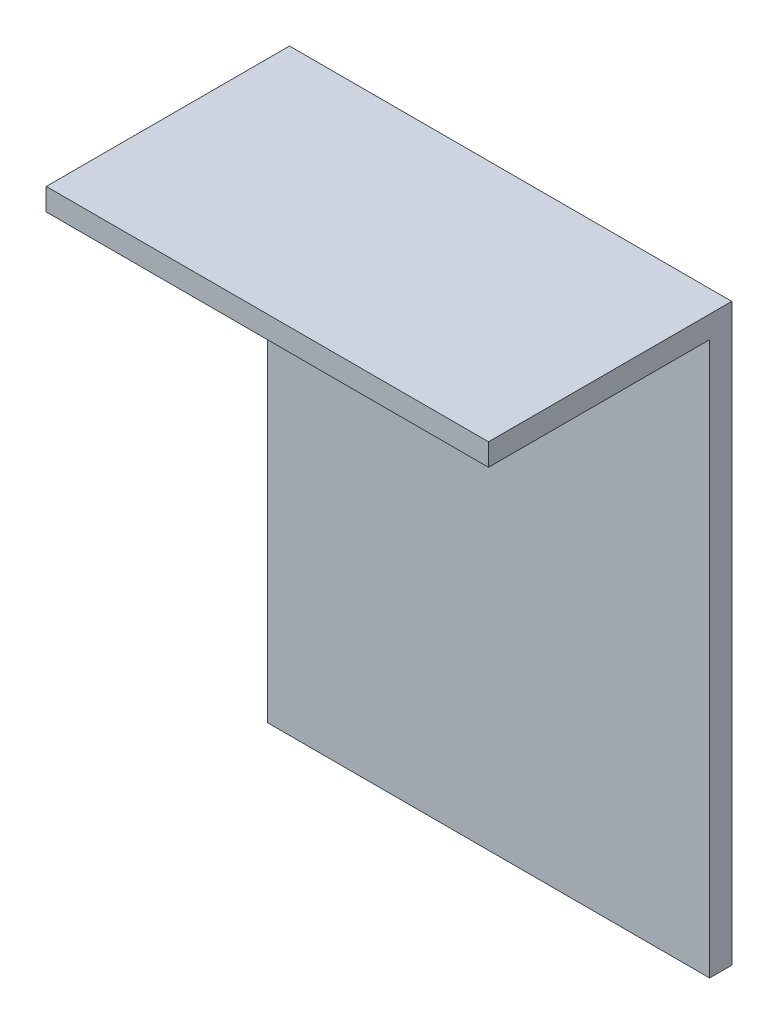
from build123d import *

# Parameters (mm, degrees)
SKETCH1_W           = 50.8
SKETCH1_H           = 66.04
BOSS_EXTRUDE1_DEPTH = 2.54
SKETCH2_W           = 50.8
SKETCH2_H           = 2.54
BOSS_EXTRUDE2_DEPTH = 25.4


with BuildPart() as part:
    # Sketch1 → Boss-Extrude1 (new body)
    with BuildSketch(Plane.XY):
        with Locations((25.4, 33.02)):
            Rectangle(SKETCH1_W, SKETCH1_H)
    extrude(amount=BOSS_EXTRUDE1_DEPTH)

    # Sketch2 → Boss-Extrude2 (add)
    with BuildSketch(Plane.XY.offset(2.54)):
        with Locations((25.4, 64.77)):
            Rectangle(SKETCH2_W, SKETCH2_H)
    extrude(amount=BOSS_EXTRUDE2_DEPTH)


solid = part.part
